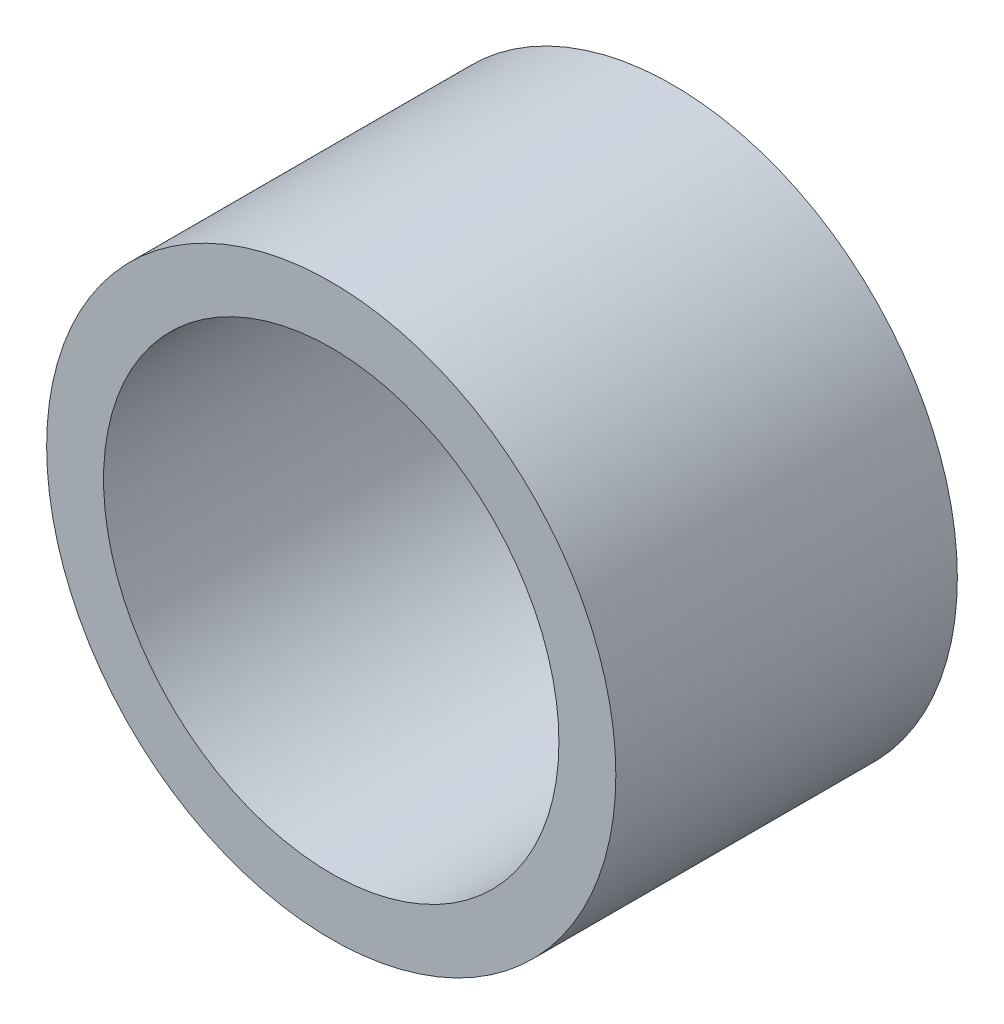
from build123d import *

# Parameters (mm, degrees)
SKETCH1_R      = 7.9375
SKETCH1_R_2    = 6.35
EXTRUDE1_DEPTH = 4.7625


with BuildPart() as part:
    # Sketch1 → Extrude1 (new body, symmetric)
    with BuildSketch(Plane.XY):
        Circle(SKETCH1_R)
        Circle(SKETCH1_R_2, mode=Mode.SUBTRACT)
    extrude(amount=EXTRUDE1_DEPTH, both=True)


solid = part.part
